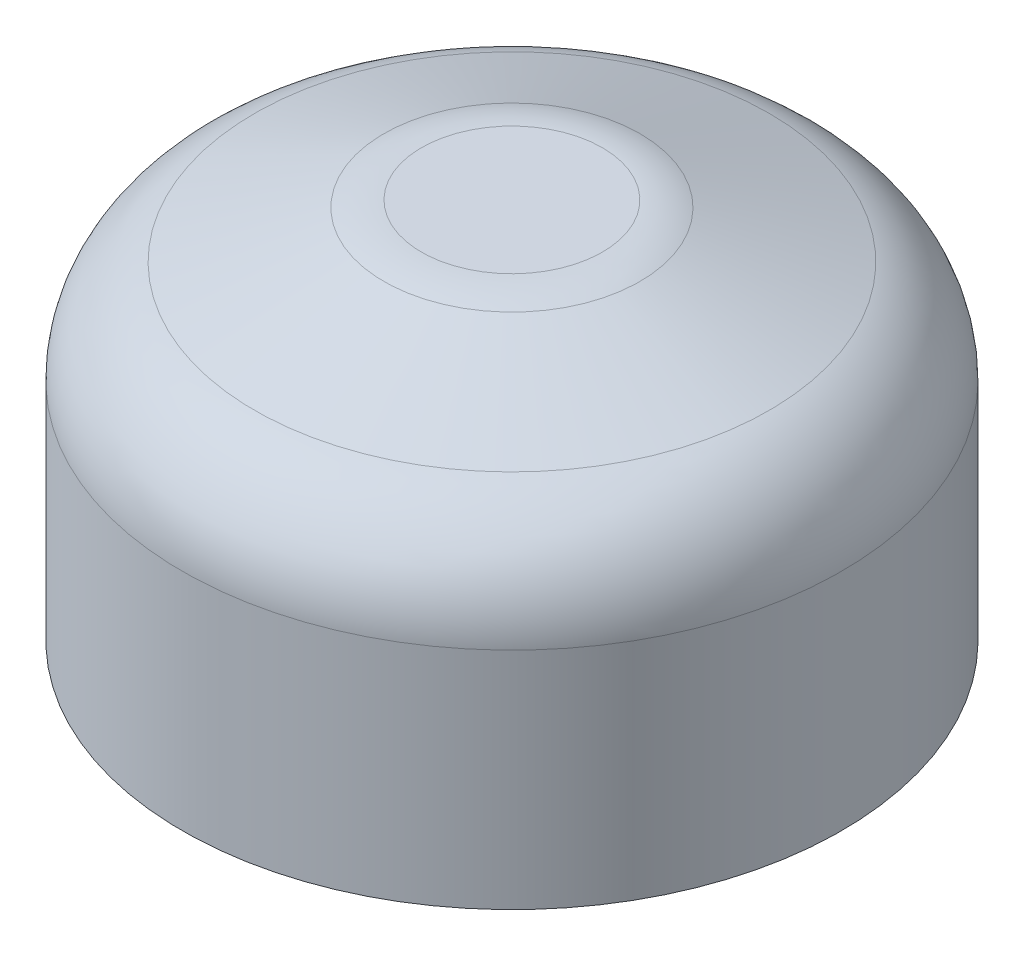
from build123d import *

# Parameters (mm, degrees)
CIRPATTERN1_COUNT = 3


with BuildPart() as part:
    # Sketch1 → Revolve1 (revolve)
    with BuildSketch(Plane.XY):
        with BuildLine():
            Line((-9.525, 6.494310079), (-9.525, 0))
            Line((-9.525, 0), (0, 0))
            Line((0, 0), (0, 11.02868))
            Line((0, 11.02868), (-2.615161836, 11.02868))
            ThreePointArc((-2.615161836, 11.02868), (-3.1664948, 10.980444616), (-3.701075791, 10.837204071))
            Line((-3.701075791, 10.837204071), (-7.435913955, 9.47783415))
            ThreePointArc((-7.435913955, 9.47783415), (-8.950807741, 8.315415264), (-9.525, 6.494310079))
        make_face()
    revolve(axis=Axis((0, -0.551434, 0), (0, 1, 0)))

    # Sketch2 → #4-40 Tapped Hole1 (revolve, cut)
    with BuildSketch(Plane(origin=(0, 0, 5.715), x_dir=(0, 0, -1), z_dir=(1, 0, 0))):
        Polygon((0, 0), (0, 9.188152758), (1.1303, 8.509), (1.1303, 0), align=None)
    f_4_40_tapped_hole1 = revolve(axis=Axis((0, -6.35, 5.715), (0, 1, 0)), mode=Mode.SUBTRACT)

    # CirPattern1: #4-40 Tapped Hole1 ×3 about axis
    cirpattern1_axis = Axis((0, 0, 0), (0, 1, 0))
    for i in range(1, CIRPATTERN1_COUNT):
        add(f_4_40_tapped_hole1.rotate(cirpattern1_axis, i * 360 / CIRPATTERN1_COUNT), mode=Mode.SUBTRACT)


solid = part.part
